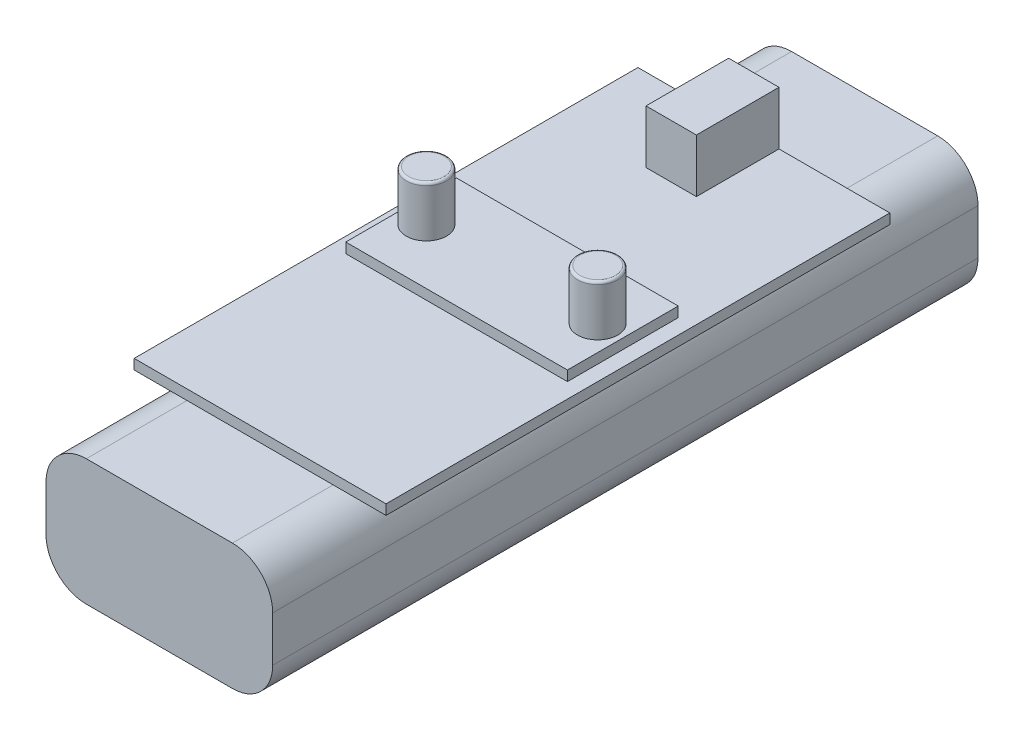
from build123d import *

# Parameters (mm, degrees)
SKIZZE1_W                       = 45
SKIZZE1_H                       = 140
AUFSATZ_LINEAR_AUSTRAGEN1_DEPTH = 25
VERRUNDUNG1_R                   = 8
SKIZZE2_W                       = 50
SKIZZE2_H                       = 100
AUFSATZ_LINEAR_AUSTRAGEN2_DEPTH = 2
SKIZZE4_W                       = 10
SKIZZE4_H                       = 16.4
AUFSATZ_LINEAR_AUSTRAGEN3_DEPTH = 10.6
SKIZZE5_W                       = 44
SKIZZE5_H                       = 22
AUFSATZ_LINEAR_AUSTRAGEN4_DEPTH = 2
SKIZZE6_R                       = 4
AUFSATZ_LINEAR_AUSTRAGEN5_DEPTH = 10
VERRUNDUNG2_R                   = 0.5


with BuildPart() as part:
    # Skizze1 → Aufsatz-Linear austragen1 (new body)
    with BuildSketch(Plane(origin=(0, 0, 0), x_dir=(1, 0, 0), z_dir=(0, 1, 0))):
        Rectangle(SKIZZE1_W, SKIZZE1_H)
    extrude(amount=AUFSATZ_LINEAR_AUSTRAGEN1_DEPTH)

    # Verrundung1
    verrundung1_edges = [part.edges().sort_by_distance(p)[0] for p in [
        (-22.5, 25, 0),
        (22.5, 25, 0),
        (-22.5, 0, 0),
        (22.5, 0, 0),
    ]]
    fillet(verrundung1_edges, radius=VERRUNDUNG1_R)

    # Skizze2 → Aufsatz-Linear austragen2 (add)
    with BuildSketch(Plane(origin=(0, 25, 0), x_dir=(1, 0, 0), z_dir=(0, 1, 0))):
        Rectangle(SKIZZE2_W, SKIZZE2_H)
    extrude(amount=AUFSATZ_LINEAR_AUSTRAGEN2_DEPTH)

    # Skizze4 → Aufsatz-Linear austragen3 (add)
    with BuildSketch(Plane(origin=(0, 27, 0), x_dir=(1, 0, 0), z_dir=(0, 1, 0))):
        with Locations((-2, 41.8)):
            Rectangle(SKIZZE4_W, SKIZZE4_H)
    extrude(amount=AUFSATZ_LINEAR_AUSTRAGEN3_DEPTH)



with BuildPart() as body_2:
    # Skizze5 → Aufsatz-Linear austragen4 (new body)
    with BuildSketch(Plane(origin=(0, 27, 0), x_dir=(1, 0, 0), z_dir=(0, 1, 0))):
        Rectangle(SKIZZE5_W, SKIZZE5_H)
    extrude(amount=AUFSATZ_LINEAR_AUSTRAGEN4_DEPTH)


with BuildPart() as part_1:
    add(part.part)

    add(body_2.part)  # Aufsatz-Linear austragen5 merges body 2
    # Skizze6 → Aufsatz-Linear austragen5 (add)
    with BuildSketch(Plane(origin=(0, 29, 0), x_dir=(1, 0, 0), z_dir=(0, 1, 0))):
        with Locations(Location((17, 0, 0), (0, 0, 90))):
            Circle(SKIZZE6_R)
        with Locations(Location((-17, 0.013570227, 0), (0, 0, 90))):
            Circle(SKIZZE6_R)
    extrude(amount=AUFSATZ_LINEAR_AUSTRAGEN5_DEPTH)

    # Verrundung2
    verrundung2_edges = [part_1.edges().sort_by_distance(p)[0] for p in [
        (17, 39, 4),
        (-17, 39, 3.986429773),
    ]]
    fillet(verrundung2_edges, radius=VERRUNDUNG2_R)


solid = part_1.part
